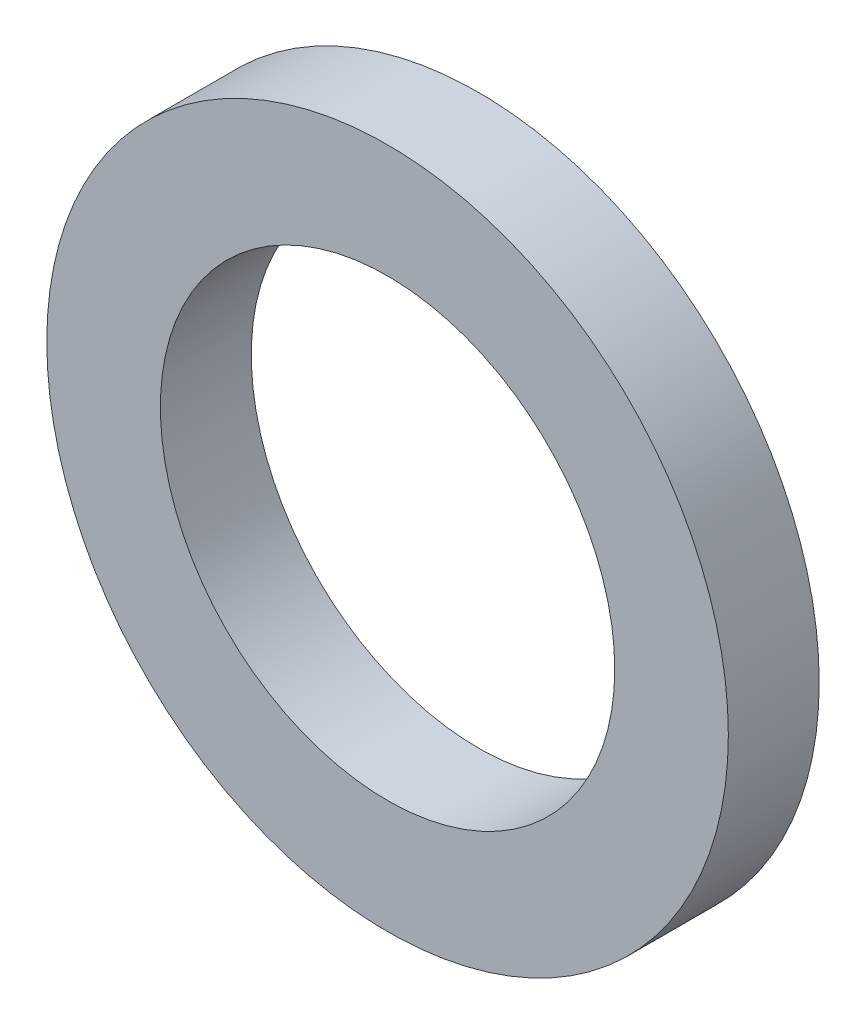
from build123d import *

# Parameters (mm, degrees)
CROQUIS1_R              = 0.75
CROQUIS1_R_2            = 0.5
SALIENTE_EXTRUIR1_DEPTH = 0.2


with BuildPart() as part:
    # Croquis1 → Saliente-Extruir1 (new body)
    with BuildSketch(Plane.XY):
        Circle(CROQUIS1_R)
        Circle(CROQUIS1_R_2, mode=Mode.SUBTRACT)
    extrude(amount=SALIENTE_EXTRUIR1_DEPTH)


solid = part.part
